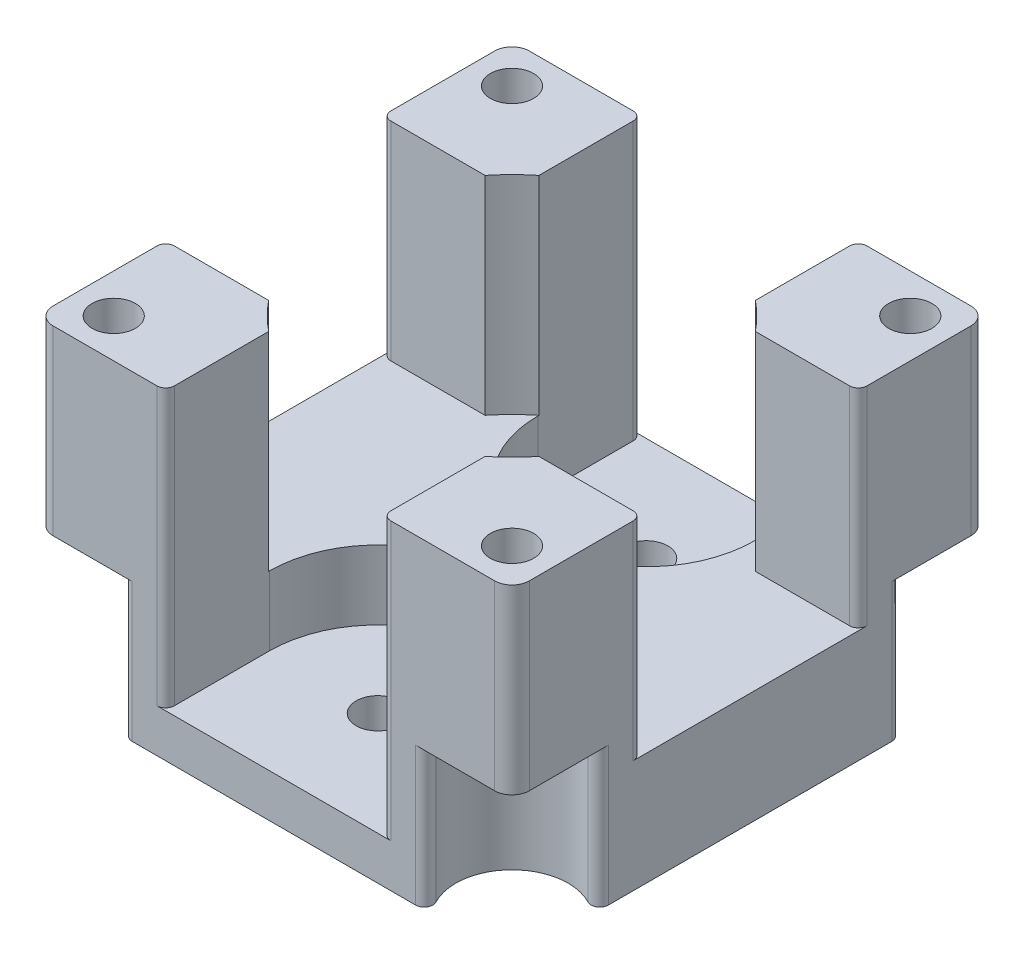
from build123d import *

# Parameters (mm, degrees)
SKETCH1_W               = 55
SKETCH1_H               = 55
BOSS_EXTRUDE1_DEPTH     = 37
SKETCH2_R               = 20
CUT_EXTRUDE1_DEPTH      = 24
SKETCH3_W               = 25
SKETCH3_H               = 55
CUT_EXTRUDE2_DEPTH      = 24
SKETCH4_W               = 55
SKETCH4_H               = 25
CUT_EXTRUDE3_DEPTH      = 24
SKETCH5_R               = 2.5
CUT_EXTRUDE4_DEPTH      = 38
SKETCH6_R               = 2.5
CUT_EXTRUDE5_DEPTH      = 38
SKETCH8_R               = 6.5
CUT_EXTRUDE6_DEPTH      = 16
CUT_EXTRUDE11_DEPTH     = 8
SKETCH16_W              = 25
SKETCH16_H              = 12
CUT_EXTRUDE12_DEPTH     = 8
SKETCH17_W              = 25
SKETCH17_H              = 12
CUT_EXTRUDE13_DEPTH     = 8
SKETCH18_R              = 2.5
CUT_EXTRUDE14_DEPTH     = 6
MIRROR5_COPY_1_SKETCH_R = 6.5
MIRROR5_COPY_1_DEPTH    = 16
FILLET2_R               = 2
FILLET3_R               = 1
FILLET4_R               = 1


with BuildPart() as part:
    # Sketch1 → Boss-Extrude1 (new body)
    with BuildSketch(Plane(origin=(0, 0, 0), x_dir=(1, 0, 0), z_dir=(0, 1, 0))):
        with Locations((27.5, 27.5)):
            Rectangle(SKETCH1_W, SKETCH1_H)
    extrude(amount=BOSS_EXTRUDE1_DEPTH)

    # Sketch2 → Cut-Extrude1 (cut)
    with BuildSketch(Plane(origin=(0, 37, 0), x_dir=(1, 0, 0), z_dir=(0, 1, 0))):
        with Locations((27.5, 27.5)):
            Circle(SKETCH2_R)
    extrude(amount=-CUT_EXTRUDE1_DEPTH, mode=Mode.SUBTRACT)

    # Sketch3 → Cut-Extrude2 (cut)
    with BuildSketch(Plane(origin=(0, 37, 0), x_dir=(1, 0, 0), z_dir=(0, 1, 0))):
        with Locations((27.5, 27.5)):
            Rectangle(SKETCH3_W, SKETCH3_H)
    cut_extrude2 = extrude(amount=-CUT_EXTRUDE2_DEPTH, mode=Mode.SUBTRACT)

    # Sketch4 → Cut-Extrude3 (cut)
    with BuildSketch(Plane(origin=(0, 37, 0), x_dir=(1, 0, 0), z_dir=(0, 1, 0))):
        with Locations((27.5, 27.5)):
            Rectangle(SKETCH4_W, SKETCH4_H)
    extrude(amount=-CUT_EXTRUDE3_DEPTH, mode=Mode.SUBTRACT)

    # Sketch5 → Cut-Extrude4 (cut, through all)
    with BuildSketch(Plane(origin=(0, 37, 0), x_dir=(1, 0, 0), z_dir=(0, 1, 0))):
        with Locations((4.5, 4.5)):
            Circle(SKETCH5_R)
    cut_extrude4 = extrude(amount=-CUT_EXTRUDE4_DEPTH, mode=Mode.SUBTRACT)

    # Sketch6 → Cut-Extrude5 (cut, through all)
    with BuildSketch(Plane(origin=(0, 37, 0), x_dir=(1, 0, 0), z_dir=(0, 1, 0))):
        with Locations((50.5, 4.5)):
            Circle(SKETCH6_R)
    cut_extrude5 = extrude(amount=-CUT_EXTRUDE5_DEPTH, mode=Mode.SUBTRACT)

    # Mirror1: Cut-Extrude4, Cut-Extrude5 across plane
    add(cut_extrude4.mirror(Plane(origin=(0, 0, -27.5), x_dir=(1, 0, 0), z_dir=(0, 0, -1))), mode=Mode.SUBTRACT)
    add(cut_extrude5.mirror(Plane(origin=(0, 0, -27.5), x_dir=(1, 0, 0), z_dir=(0, 0, -1))), mode=Mode.SUBTRACT)

    # Sketch8 → Cut-Extrude6 (cut)
    with BuildSketch(Plane.XZ):
        with Locations((50.5, -50.5)):
            Circle(SKETCH8_R)
    cut_extrude6 = extrude(amount=-CUT_EXTRUDE6_DEPTH, mode=Mode.SUBTRACT)

    # Sketch15 → Cut-Extrude11 (cut)
    with BuildSketch(Plane(origin=(0, 13, 0), x_dir=(1, 0, 0), z_dir=(0, 1, 0))):
        with BuildLine():
            ThreePointArc((24, 55), (20, 33), (40, 43))
            ThreePointArc((40, 43), (37.5, 50.5), (31, 55))
            Line((31, 55), (24, 55))
        make_face()
        with BuildLine():
            Line((24, 55), (31, 55))
            ThreePointArc((31, 55), (27.5, 55.5), (24, 55))
        make_face()
    cut_extrude11 = extrude(amount=-CUT_EXTRUDE11_DEPTH, mode=Mode.SUBTRACT)

    # Sketch16 → Cut-Extrude12 (cut)
    with BuildSketch(Plane(origin=(0, 13, 0), x_dir=(1, 0, 0), z_dir=(0, 1, 0))):
        with Locations((27.5, 49)):
            Rectangle(SKETCH16_W, SKETCH16_H)
    extrude(amount=-CUT_EXTRUDE12_DEPTH, mode=Mode.SUBTRACT)

    # Mirror2: Cut-Extrude2, Cut-Extrude11 across plane
    add(cut_extrude2.mirror(Plane(origin=(0, 0, -27.5), x_dir=(1, 0, 0), z_dir=(0, 0, -1))), mode=Mode.SUBTRACT)
    add(cut_extrude11.mirror(Plane(origin=(0, 0, -27.5), x_dir=(1, 0, 0), z_dir=(0, 0, -1))), mode=Mode.SUBTRACT)

    # Sketch17 → Cut-Extrude13 (cut)
    with BuildSketch(Plane(origin=(0, 13, 0), x_dir=(1, 0, 0), z_dir=(0, 1, 0))):
        with Locations((27.5, 6)):
            Rectangle(SKETCH17_W, SKETCH17_H)
    extrude(amount=-CUT_EXTRUDE13_DEPTH, mode=Mode.SUBTRACT)

    # Sketch18 → Cut-Extrude14 (cut, through all)
    with BuildSketch(Plane(origin=(0, 5, 0), x_dir=(1, 0, 0), z_dir=(0, 1, 0))):
        with Locations((27.5, 43)):
            Circle(SKETCH18_R)
    cut_extrude14 = extrude(amount=-CUT_EXTRUDE14_DEPTH, mode=Mode.SUBTRACT)

    # Mirror3: Cut-Extrude14 across plane
    add(cut_extrude14.mirror(Plane(origin=(0, 0, -27.5), x_dir=(1, 0, 0), z_dir=(0, 0, -1))), mode=Mode.SUBTRACT)

    # Mirror4: Cut-Extrude6 across plane
    add(cut_extrude6.mirror(Plane(origin=(27.5, 0, 0), x_dir=(0, 0, 1), z_dir=(1, 0, 0))), mode=Mode.SUBTRACT)

    # Mirror5: Cut-Extrude6 across plane
    add(cut_extrude6.mirror(Plane(origin=(0, 0, -27.5), x_dir=(1, 0, 0), z_dir=(0, 0, -1))), mode=Mode.SUBTRACT)

    # Mirror5 copy 1 sketch → Mirror5 copy 1 (cut)
    with BuildSketch(Plane(origin=(55, 0, -55), x_dir=(-1, 0, 0), z_dir=(0, -1, 0))):
        with Locations((50.5, -50.5)):
            Circle(MIRROR5_COPY_1_SKETCH_R)
    extrude(amount=-MIRROR5_COPY_1_DEPTH, mode=Mode.SUBTRACT)

    # Fillet2
    fillet2_edges = [part.edges().sort_by_distance(p)[0] for p in [
        (0, 26.5, -55),
        (55, 26.5, -55),
        (55, 26.5, 0),
        (0, 26.5, 0),
    ]]
    fillet(fillet2_edges, radius=FILLET2_R)

    # Fillet3
    fillet3_edges = [part.edges().sort_by_distance(p)[0] for p in [
        (55, 8, -45.80958424),
        (45.80958424, 8, -55),
        (0, 8, -45.80958424),
        (9.19041576, 8, -55),
        (0, 8, -9.19041576),
        (9.19041576, 8, 0),
        (45.80958424, 8, 0),
        (55, 8, -9.19041576),
    ]]
    fillet(fillet3_edges, radius=FILLET3_R)

    # Fillet4
    fillet4_edges = [part.edges().sort_by_distance(p)[0] for p in [
        (15, 21, 0),
        (40, 21, -55),
        (15, 21, -55),
        (40, 21, 0),
        (0, 25, -40),
        (55, 25, -15),
        (0, 25, -15),
        (55, 25, -40),
    ]]
    fillet(fillet4_edges, radius=FILLET4_R)


solid = part.part
